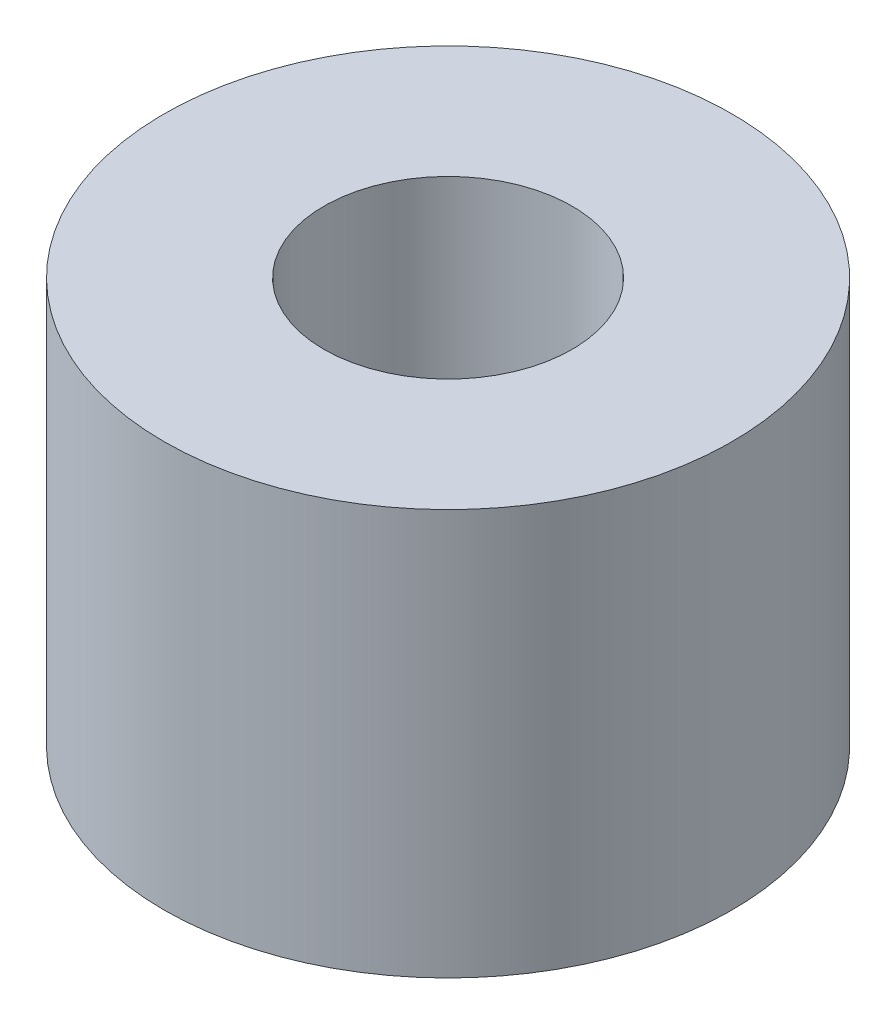
from build123d import *

# Parameters (mm, degrees)
CROQUIS1_R              = 3.5
CROQUIS1_R_2            = 1.53
SALIENTE_EXTRUIR1_DEPTH = 5


with BuildPart() as part:
    # Croquis1 → Saliente-Extruir1 (new body)
    with BuildSketch(Plane(origin=(0, 0, 0), x_dir=(1, 0, 0), z_dir=(0, 1, 0))):
        Circle(CROQUIS1_R)
        Circle(CROQUIS1_R_2, mode=Mode.SUBTRACT)
    extrude(amount=SALIENTE_EXTRUIR1_DEPTH)


solid = part.part
